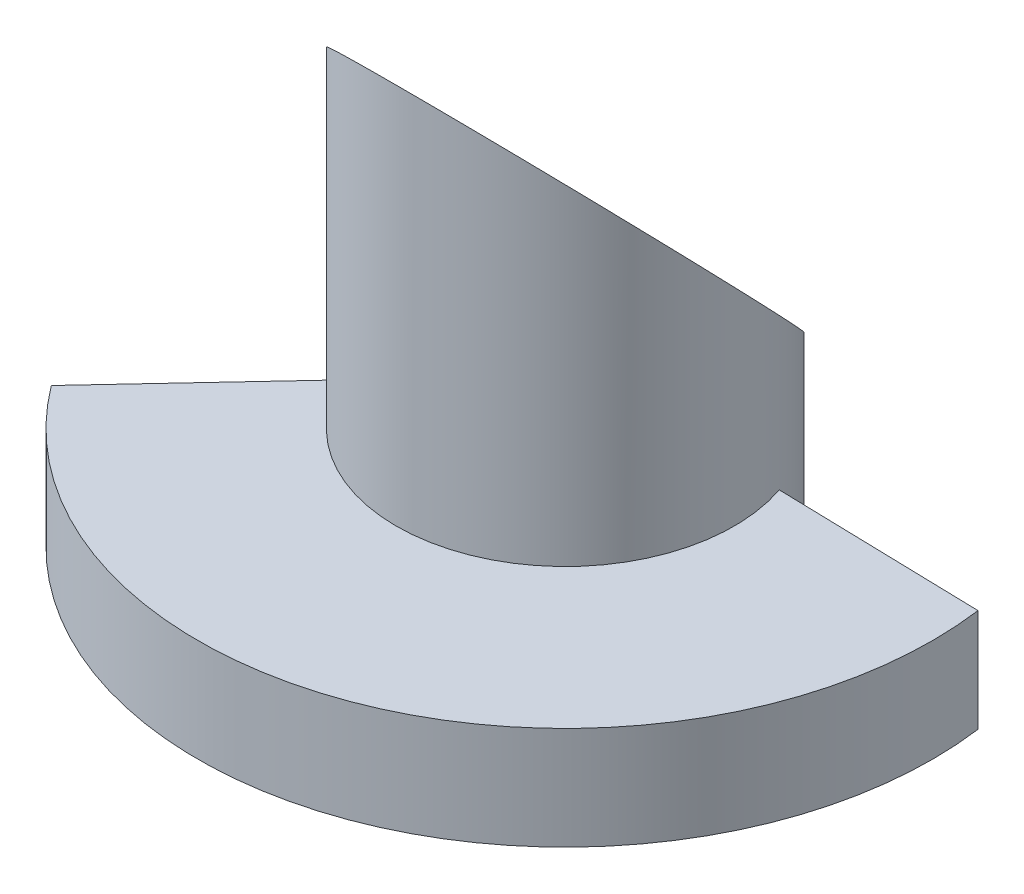
from build123d import *

# Parameters (mm, degrees)
BOSS_EXTRUDE1_DEPTH     = 7
SKETCH2_R               = 11.5
BOSS_EXTRUDE2_DEPTH     = 26
CUT_EXTRUDE1_DEPTH      = 26
CUT_EXTRUDE1_DEPTH_BACK = 26


with BuildPart() as part:
    # Sketch1 → Boss-Extrude1 (new body)
    with BuildSketch(Plane(origin=(0, 0, 0), x_dir=(1, 0, 0), z_dir=(0, 1, 0))):
        with BuildLine():
            Line((24.778235728, 3.32250421), (10.896730509, 3.67576716))
            ThreePointArc((10.896730509, 3.67576716), (-4.207828527, 10.702531433), (-10.482370924, -4.729682845))
            Line((-10.482370924, -4.729682845), (-20.036775025, -14.950841))
            ThreePointArc((-20.036775025, -14.950841), (9.439234539, -23.149532421), (24.778235728, 3.32250421))
        make_face()
    extrude(amount=BOSS_EXTRUDE1_DEPTH)

    # Sketch2 → Boss-Extrude2 (add)
    with BuildSketch(Plane(origin=(0, 7, 0), x_dir=(1, 0, 0), z_dir=(0, 1, 0))):
        Circle(SKETCH2_R)
    extrude(amount=BOSS_EXTRUDE2_DEPTH)

    # Sketch5 → Cut-Extrude1 (cut, two sides: drawn at the far end of the back side and taken through both)
    with BuildSketch(Plane(origin=(0, 0, 0), x_dir=(0, 0, -1), z_dir=(1, 0, 0)).offset(-CUT_EXTRUDE1_DEPTH_BACK)):
        Polygon((11.5, 33), (-11.5, 33), (11.5, 9.182802783), align=None)
    extrude(amount=CUT_EXTRUDE1_DEPTH + CUT_EXTRUDE1_DEPTH_BACK, mode=Mode.SUBTRACT)


solid = part.part
